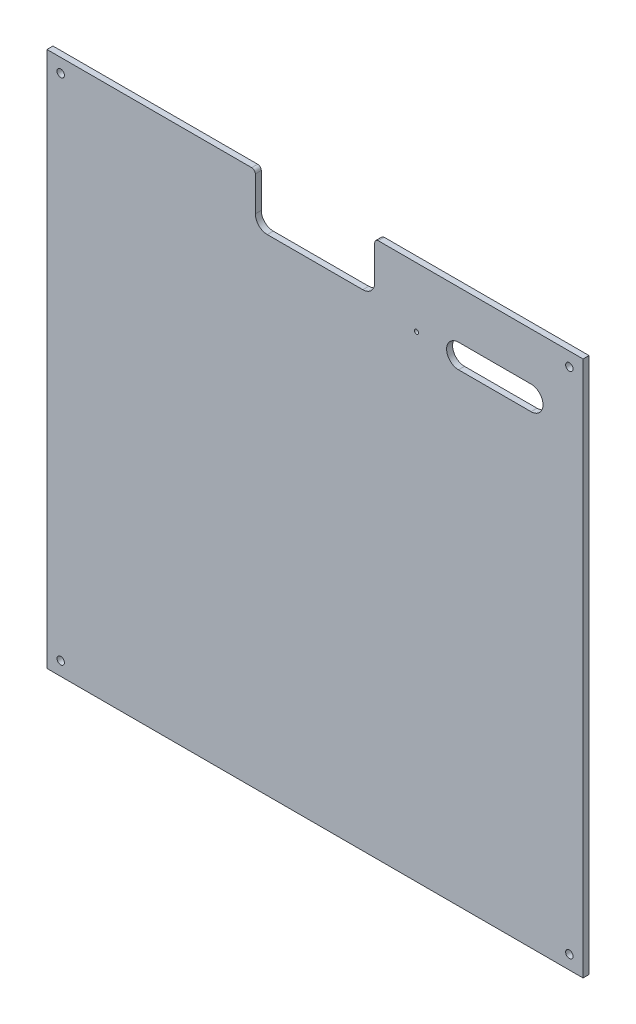
from build123d import *

# Parameters (mm, degrees)
SCHIZZO1_R                   = 3.1
SCHIZZO1_R_2                 = 1.75
ESTRUSIONE_ESTRUSIONE1_DEPTH = 5


with BuildPart() as part:
    # Schizzo1 → Estrusione-Estrusione1 (new body)
    with BuildSketch(Plane.XY):
        with BuildLine():
            Line((0, 0), (0, 449))
            Line((0, 449), (171.5, 449))
            ThreePointArc((171.5, 449), (173.621320344, 448.121320344), (174.5, 446))
            Line((174.5, 446), (174.5, 417))
            ThreePointArc((174.5, 417), (177.428932188, 409.928932188), (184.5, 407))
            Line((184.5, 407), (264.5, 407))
            ThreePointArc((264.5, 407), (271.571067812, 409.928932188), (274.5, 417))
            Line((274.5, 417), (274.5, 446))
            ThreePointArc((274.5, 446), (275.378679656, 448.121320344), (277.5, 449))
            Line((277.5, 449), (449, 449))
            Line((449, 449), (449, 0))
            Line((449, 0), (0, 0))
        make_face()
        with Locations((11.5, 11.5)):
            Circle(SCHIZZO1_R, mode=Mode.SUBTRACT)
        with Locations((437.5, 11.5)):
            Circle(SCHIZZO1_R, mode=Mode.SUBTRACT)
        with Locations((437.5, 437.5)):
            Circle(SCHIZZO1_R, mode=Mode.SUBTRACT)
        with Locations((11.5, 437.5)):
            Circle(SCHIZZO1_R, mode=Mode.SUBTRACT)
        with Locations((309.5, 399)):
            Circle(SCHIZZO1_R_2, mode=Mode.SUBTRACT)
        with BuildLine():
            Line((344.715899345, 409), (405.440355678, 409))
            ThreePointArc((405.440355678, 409), (415.440355678, 399), (405.440355678, 389))
            Line((405.440355678, 389), (344.715899345, 389))
            ThreePointArc((344.715899345, 389), (334.715899345, 399), (344.715899345, 409))
        make_face(mode=Mode.SUBTRACT)
    extrude(amount=ESTRUSIONE_ESTRUSIONE1_DEPTH)


solid = part.part
